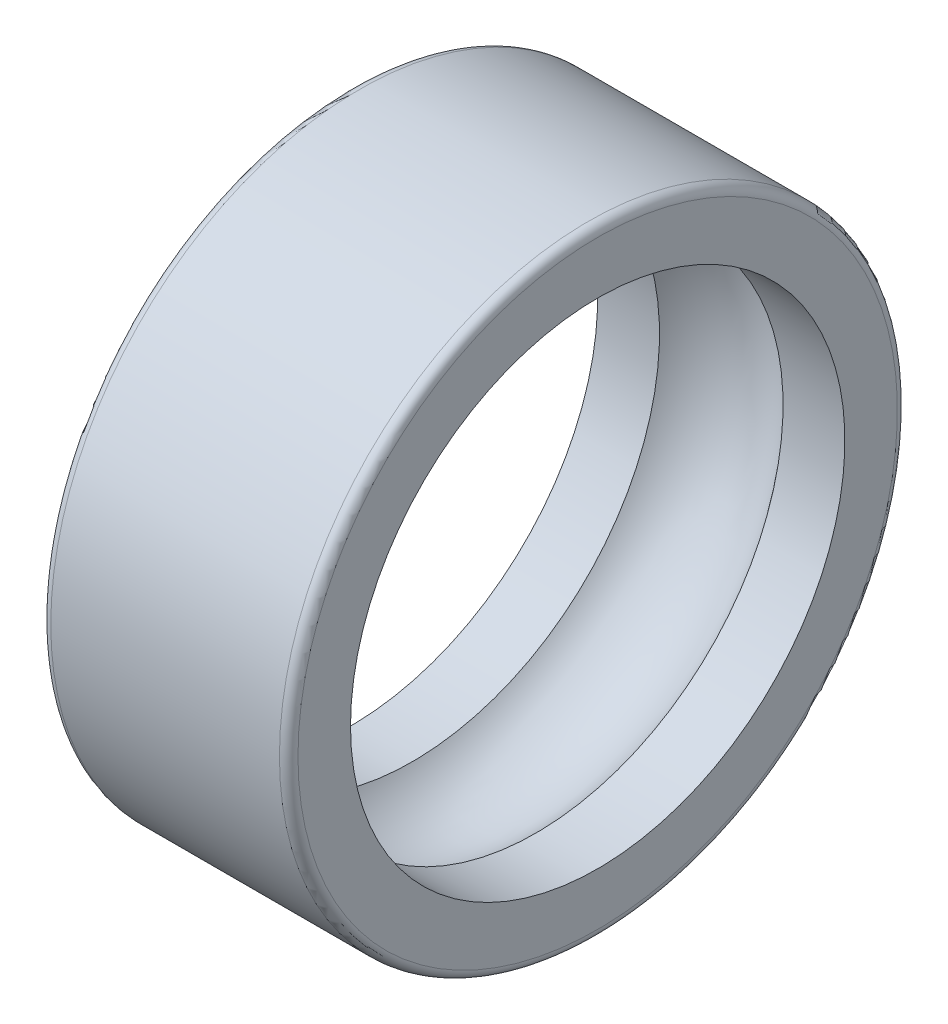
from build123d import *

# Parameters (mm, degrees)
CONG_1_R = 0.15


with BuildPart() as part:
    # Esquisse1 → Base-Révolution (revolve)
    with BuildSketch(Plane.XY):
        with BuildLine():
            Line((0, 4), (1, 4))
            ThreePointArc((1, 4), (2, 4.5), (3, 4))
            Line((3, 4), (4, 4))
            Line((4, 4), (4, 5))
            Line((4, 5), (0, 5))
            Line((0, 5), (0, 4))
        make_face()
    revolve(axis=Axis((0, 0, 0), (1, 0, 0)))

    # Congé1
    cong_1_edges = [part.edges().sort_by_distance(p)[0] for p in [
        (4, -5, 0),
        (0, -5, 0),
    ]]
    fillet(cong_1_edges, radius=CONG_1_R)


solid = part.part
